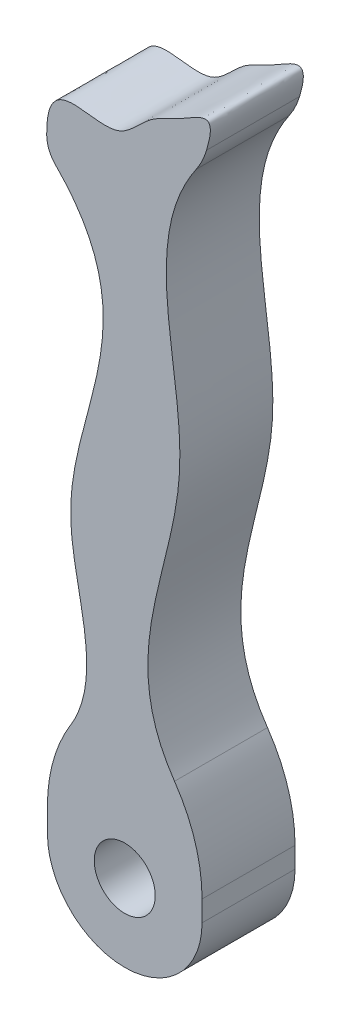
from build123d import *

# Parameters (mm, degrees)
SKETCH1_R           = 1.968584464
BOSS_EXTRUDE2_DEPTH = 6
FILLET4_R           = 5
FILLET6_R           = 2
FILLET7_R           = 10
FILLET8_R           = 10
FILLET10_R          = 1
FILLET11_R          = 1
CUT_EXTRUDE1_DEPTH  = 10


with BuildPart() as part:
    # Sketch1 → Boss-Extrude2 (new body)
    with BuildSketch(Plane.XY):
        with BuildLine():
            Line((0, 0), (0, -9.98))
            Line((0, -9.98), (9.98, -9.98))
            Line((9.98, -9.98), (9.98, 0))
            add(Edge.make_bspline(
                [(9.98, 37.459838996), (5.582240321, 31.754849972), (12.492520243, 18.672418011), (3.340825824, 6.221702166), (9.98, 0)],
                knots=[0, 0, 0, 0, 0.478051335, 1, 1, 1, 1], degree=3))
            add(Edge.make_bspline(
                [(0, 33.141730679), (-0.475525657, 38.477983596), (3.957816191, 34.827903257), (6.4220881, 38.386082907), (9.108108181, 39.295033573), (11.329672234, 41.241349396), (9.98, 37.459838996)],
                knots=[0, 0, 0, 0, 0.419249338, 0.591045552, 0.727790706, 1, 1, 1, 1], degree=3))
            add(Edge.make_bspline(
                [(0, 33.141730679), (7.183564459, 26.576095652), (-2.679225241, 15.509345178), (4.562219574, 4.334652236), (0, 0)],
                knots=[0, 0, 0, 0, 0.589573003, 1, 1, 1, 1], degree=3))
        make_face()
        with Locations((4.99, -4.99)):
            Circle(SKETCH1_R, mode=Mode.SUBTRACT)
    extrude(amount=BOSS_EXTRUDE2_DEPTH)

    # Fillet4
    fillet4_edges = [part.edges().sort_by_distance(p)[0] for p in [
        (9.98, 37.459838996, 3),
    ]]
    fillet(fillet4_edges, radius=FILLET4_R)

    # Fillet6
    fillet6_edges = [part.edges().sort_by_distance(p)[0] for p in [
        (0, 33.141730679, 3),
    ]]
    fillet(fillet6_edges, radius=FILLET6_R)

    # Fillet7
    fillet7_edges = [part.edges().sort_by_distance(p)[0] for p in [
        (0, 0, 3),
    ]]
    fillet(fillet7_edges, radius=FILLET7_R)

    # Fillet8
    fillet8_edges = [part.edges().sort_by_distance(p)[0] for p in [
        (9.98, 0, 3),
    ]]
    fillet(fillet8_edges, radius=FILLET8_R)

    # Fillet10
    fillet10_edges = [part.edges().sort_by_distance(p)[0] for p in [
        (9.98, -9.98, 3),
    ]]
    fillet(fillet10_edges, radius=FILLET10_R)

    # Fillet11
    fillet11_edges = [part.edges().sort_by_distance(p)[0] for p in [
        (0, -9.98, 3),
    ]]
    fillet(fillet11_edges, radius=FILLET11_R)

    # Sketch2 → Cut-Extrude1 (cut)
    with BuildSketch(Plane.XY.offset(6)):
        with BuildLine():
            Line((9.98, -8.98), (9.98, -4.99))
            ThreePointArc((9.98, -4.99), (8.518462838, -8.518462838), (4.99, -9.98))
            Line((4.99, -9.98), (8.98, -9.98))
            ThreePointArc((8.98, -9.98), (9.687106781, -9.687106781), (9.98, -8.98))
        make_face()
        with BuildLine():
            ThreePointArc((4.99, -9.98), (1.461537162, -8.518462838), (0, -4.99))
            Line((0, -4.99), (0, -8.98))
            ThreePointArc((0, -8.98), (0.292893219, -9.687106781), (1, -9.98))
            Line((1, -9.98), (4.99, -9.98))
        make_face()
    extrude(amount=-CUT_EXTRUDE1_DEPTH, mode=Mode.SUBTRACT)


solid = part.part
